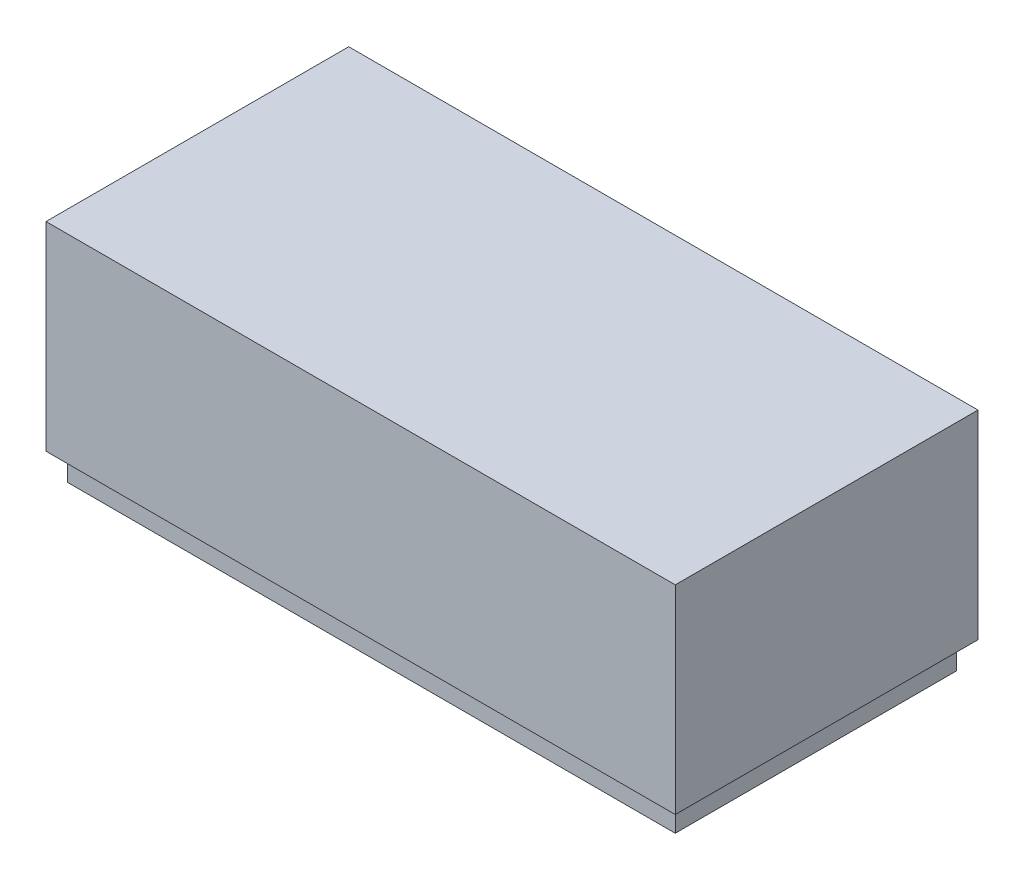
from build123d import *

# Parameters (mm, degrees)
SKETCH_1_W      = 58.2
SKETCH_1_H      = 28
EXTRUDE_1_DEPTH = 18.4
SKETCH_2_W      = 56.2
SKETCH_2_H      = 26
EXTRUDE_2_DEPTH = 2.5


with BuildPart() as part:
    # 草图1 → 凸台-拉伸1 (new body)
    with BuildSketch(Plane(origin=(0, 0, 0), x_dir=(1, 0, 0), z_dir=(0, 1, 0))):
        Rectangle(SKETCH_1_W, SKETCH_1_H)
    extrude(amount=EXTRUDE_1_DEPTH)

    # 草图2 → 凸台-拉伸2 (add)
    with BuildSketch(Plane.XZ):
        Rectangle(SKETCH_2_W, SKETCH_2_H)
    extrude(amount=EXTRUDE_2_DEPTH)


solid = part.part
